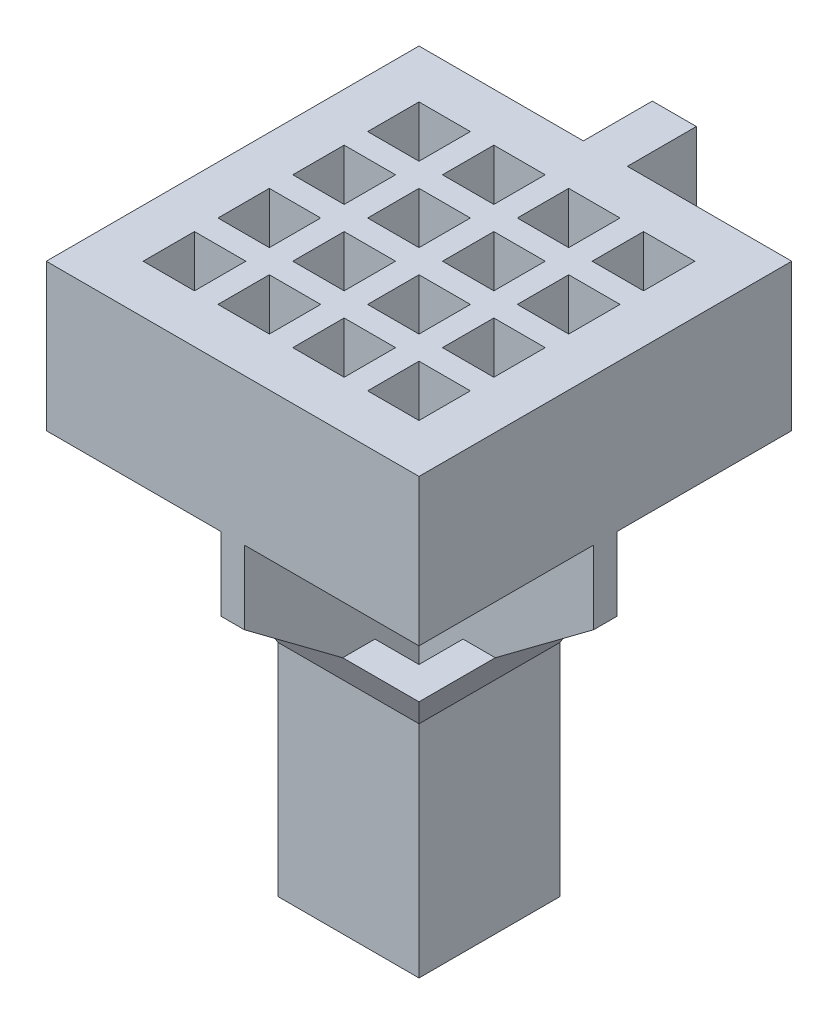
from build123d import *

# Parameters (mm, degrees)
TOP_PANEL_W               = 2.54
TOP_PANEL_H               = 2.54
BOSS_EXTRUDE1_DEPTH       = 1
WELL_HOLES_W              = 0.35
WELL_HOLES_H              = 0.35
WELLS_DEPTH               = 1
SKETCH5_W                 = 2.54
SKETCH5_H                 = 0.16
BOSS_EXTRUDE5_DEPTH       = 0.5
SKETCH4_W                 = 1.2
SKETCH4_H                 = 0.16
SUPPORT_WALL_SKETCH_W     = 0.16
SUPPORT_WALL_SKETCH_H     = 2.54
BOSS_EXTRUDE7_DEPTH       = 0.5
SKETCH7_W                 = 0.16
SKETCH7_H                 = 0.52
SKETCH7_3_W               = 0.16
SKETCH7_3_H               = 0.52
SKETCH8_W                 = 1.2
SKETCH8_H                 = 1.2
SKETCH9_W                 = 0.96
SKETCH9_H                 = 0.96
SKETCH9_2_W               = 0.96
SKETCH9_2_H               = 0.96
TETRODE_GUIDE_DEPTH       = 1.5
TETRODE_ENTRY_HOLDES_W    = 0.3
TETRODE_ENTRY_HOLDES_H    = 0.3
TETRODE_GUIDE_HOLES_DEPTH = 1.75
SKETCH10_W                = 0.3
SKETCH10_H                = 0.8
TAB_DEPTH                 = 1


with BuildPart() as part:
    # top_panel → Boss-Extrude1 (new body)
    with BuildSketch(Plane(origin=(0, 0, 0), x_dir=(1, 0, 0), z_dir=(0, 1, 0))):
        with Locations((-17.144369017, 12.374381862)):
            Rectangle(TOP_PANEL_W, TOP_PANEL_H)
    extrude(amount=-BOSS_EXTRUDE1_DEPTH)

    # well_holes → wells (cut)
    with BuildSketch(Plane(origin=(0, 0, 0), x_dir=(1, 0, 0), z_dir=(0, 1, 0))):
        with Locations((-17.399369017, 13.139381862)):
            Rectangle(WELL_HOLES_W, WELL_HOLES_H)
        with Locations((-17.909369017, 13.139381862)):
            Rectangle(WELL_HOLES_W, WELL_HOLES_H)
        with Locations((-16.889369017, 13.139381862)):
            Rectangle(WELL_HOLES_W, WELL_HOLES_H)
        with Locations((-16.379369017, 13.139381862)):
            Rectangle(WELL_HOLES_W, WELL_HOLES_H)
        with Locations((-17.399369017, 12.629381862)):
            Rectangle(WELL_HOLES_W, WELL_HOLES_H)
        with Locations((-16.889369017, 12.629381862)):
            Rectangle(WELL_HOLES_W, WELL_HOLES_H)
        with Locations((-16.379369017, 12.629381862)):
            Rectangle(WELL_HOLES_W, WELL_HOLES_H)
        with Locations((-17.399369017, 12.119381862)):
            Rectangle(WELL_HOLES_W, WELL_HOLES_H)
        with Locations((-16.889369017, 12.119381862)):
            Rectangle(WELL_HOLES_W, WELL_HOLES_H)
        with Locations((-16.379369017, 12.119381862)):
            Rectangle(WELL_HOLES_W, WELL_HOLES_H)
        with Locations((-17.399369017, 11.609381862)):
            Rectangle(WELL_HOLES_W, WELL_HOLES_H)
        with Locations((-16.889369017, 11.609381862)):
            Rectangle(WELL_HOLES_W, WELL_HOLES_H)
        with Locations((-16.379369017, 11.609381862)):
            Rectangle(WELL_HOLES_W, WELL_HOLES_H)
        with Locations((-17.909369017, 12.629381862)):
            Rectangle(WELL_HOLES_W, WELL_HOLES_H)
        with Locations((-17.909369017, 12.119381862)):
            Rectangle(WELL_HOLES_W, WELL_HOLES_H)
        with Locations((-17.909369017, 11.609381862)):
            Rectangle(WELL_HOLES_W, WELL_HOLES_H)
    extrude(amount=-WELLS_DEPTH, mode=Mode.SUBTRACT)

    # Sketch5 → Boss-Extrude5 (add)
    with BuildSketch(Plane(origin=(0, -1, 0), x_dir=(-1, 0, 0), z_dir=(0, -1, 0))):
        with Locations((17.144369017, 12.374381862)):
            Rectangle(SKETCH5_W, SKETCH5_H)
    extrude(amount=BOSS_EXTRUDE5_DEPTH)

    # Sketch4 → section 1 of loft3
    with BuildSketch(Plane(origin=(0, -2, 0), x_dir=(1, 0, 0), z_dir=(0, 1, 0)), mode=Mode.PRIVATE) as loft3_s1:
        with Locations((-17.144369017, 12.374381862)):
            Rectangle(SKETCH4_W, SKETCH4_H)
    # loft from a face of the part (loft3)
    loft([part.faces().sort_by_distance((-17.144369017, -1.5, -12.374381862))[0], loft3_s1.sketch])

    # support_wall_sketch → Boss-Extrude7 (add)
    with BuildSketch(Plane(origin=(0, -1, 0), x_dir=(-1, 0, 0), z_dir=(0, -1, 0))):
        with Locations((17.144369017, 12.374381862)):
            Rectangle(SUPPORT_WALL_SKETCH_W, SUPPORT_WALL_SKETCH_H)
    extrude(amount=BOSS_EXTRUDE7_DEPTH)

    # Sketch7 → section 1 of loft6
    with BuildSketch(Plane(origin=(0, -2, 0), x_dir=(1, 0, 0), z_dir=(0, 1, 0)), mode=Mode.PRIVATE) as loft6_s1:
        with Locations((-17.144369017, 12.034381862)):
            Rectangle(SKETCH7_W, SKETCH7_H)
    # loft from a face of the part (loft6)
    loft([part.faces().sort_by_distance((-17.144369017, -1.5, -11.699381862))[0], loft6_s1.sketch])

    # Sketch7_3 → section 1 of loft7
    with BuildSketch(Plane(origin=(0, -2, 0), x_dir=(1, 0, 0), z_dir=(0, 1, 0)), mode=Mode.PRIVATE) as loft7_s1:
        with Locations((-17.144369017, 12.714381862)):
            Rectangle(SKETCH7_3_W, SKETCH7_3_H)
    # loft from a face of the part (loft7)
    loft([part.faces().sort_by_distance((-17.144369017, -1.5, -13.049381862))[0], loft7_s1.sketch])

    # Sketch8 → mezzanine section 0
    with BuildSketch(Plane(origin=(0, -2, 0), x_dir=(1, 0, 0), z_dir=(0, 1, 0))):
        with Locations((-17.144369017, 12.374381862)):
            Rectangle(SKETCH8_W, SKETCH8_H)
    # Sketch9 → mezzanine section 1
    with BuildSketch(Plane(origin=(0, -2.25, 0), x_dir=(1, 0, 0), z_dir=(0, 1, 0))):
        with Locations((-17.144369017, 12.374381862)):
            Rectangle(SKETCH9_W, SKETCH9_H)
    loft()

    # Sketch9_2 → tetrode_guide (add)
    with BuildSketch(Plane(origin=(0, -2.25, 0), x_dir=(1, 0, 0), z_dir=(0, 1, 0))):
        with Locations((-17.144369017, 12.374381862)):
            Rectangle(SKETCH9_2_W, SKETCH9_2_H)
    extrude(amount=-TETRODE_GUIDE_DEPTH)

    # tetrode_entry_holdes → tetrode_guide_holes (cut)
    with BuildSketch(Plane(origin=(0, -2, 0), x_dir=(1, 0, 0), z_dir=(0, 1, 0))):
        with Locations((-17.374369017, 12.144381862)):
            Rectangle(TETRODE_ENTRY_HOLDES_W, TETRODE_ENTRY_HOLDES_H)
        with Locations((-16.914369017, 12.144381862)):
            Rectangle(TETRODE_ENTRY_HOLDES_W, TETRODE_ENTRY_HOLDES_H)
        with Locations((-16.914369017, 12.604381862)):
            Rectangle(TETRODE_ENTRY_HOLDES_W, TETRODE_ENTRY_HOLDES_H)
        with Locations((-17.374369017, 12.604381862)):
            Rectangle(TETRODE_ENTRY_HOLDES_W, TETRODE_ENTRY_HOLDES_H)
    extrude(amount=-TETRODE_GUIDE_HOLES_DEPTH, mode=Mode.SUBTRACT)

    # Sketch10 → tab (add)
    with BuildSketch(Plane(origin=(0, 0, 0), x_dir=(1, 0, 0), z_dir=(0, 1, 0))):
        with Locations((-17.144369017, 13.714381862)):
            Rectangle(SKETCH10_W, SKETCH10_H)
    extrude(amount=-TAB_DEPTH)


solid = part.part
